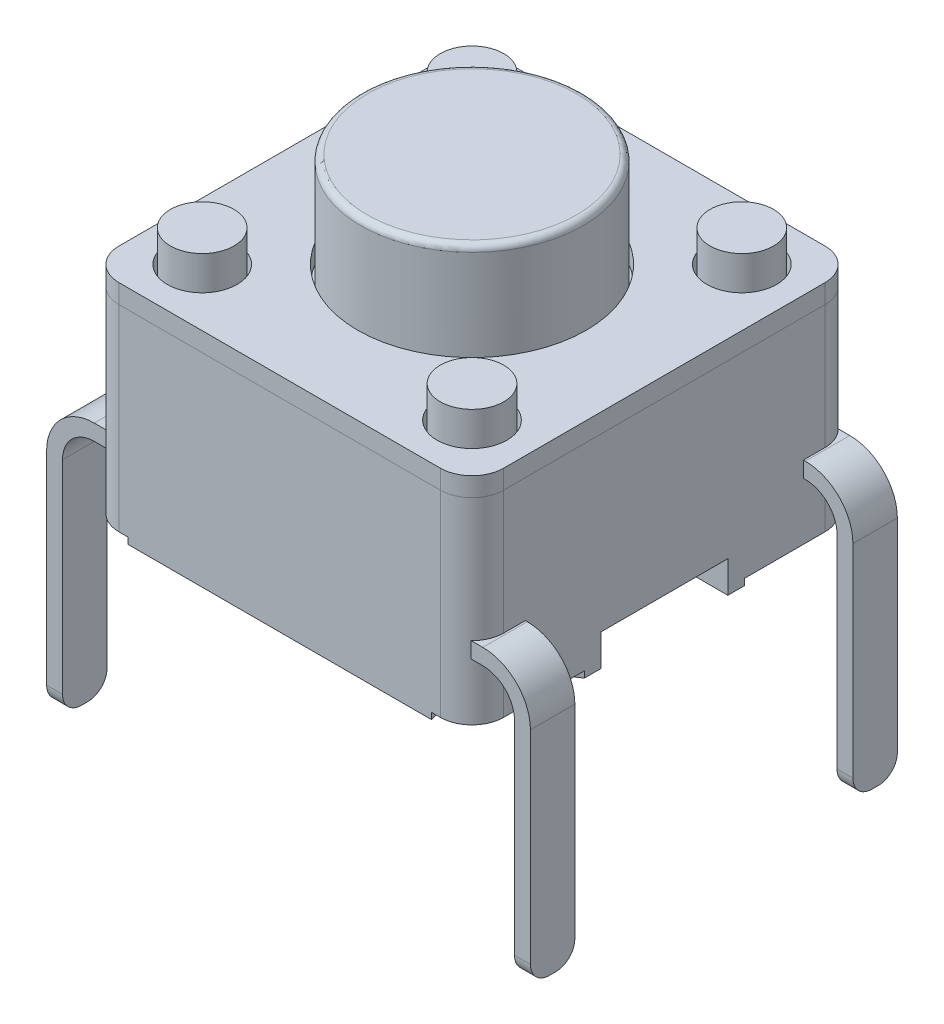
from build123d import *

# Parameters (mm, degrees)
SKETCH1_W           = 6.06
SKETCH1_H           = 6.06
BOSS_EXTRUDE1_DEPTH = 0.3
SKETCH2_W           = 6.06
SKETCH2_H           = 6.06
BOSS_EXTRUDE2_DEPTH = 3.2
SKETCH3_R           = 1.8
SKETCH3_R_2         = 0.55
CUT_EXTRUDE1_DEPTH  = 0.3
FILLET1_R           = 0.5
FILLET2_R           = 0.5
SKETCH5_R           = 0.5
BOSS_EXTRUDE4_DEPTH = 0.8
SKETCH6_R           = 1.75
BOSS_EXTRUDE5_DEPTH = 1.8
FILLET4_R           = 0.1
SKETCH7_W           = 2
SKETCH7_H           = 0.5
CUT_EXTRUDE2_DEPTH  = 6.06
EXTRUDE_THIN1_DEPTH = 0.35
FILLET5_R           = 0.3
LPATTERN1_COUNT     = 2
LPATTERN1_PITCH     = 5.08
SKETCH9_R           = 1.5
CUT_EXTRUDE4_DEPTH  = 0.1


with BuildPart() as part:
    # Sketch1 → Boss-Extrude1 (new body)
    with BuildSketch(Plane(origin=(0, 0, 0), x_dir=(1, 0, 0), z_dir=(0, 1, 0))):
        Rectangle(SKETCH1_W, SKETCH1_H)
    extrude(amount=-BOSS_EXTRUDE1_DEPTH)

    # Sketch3 → Cut-Extrude1 (cut)
    with BuildSketch(Plane(origin=(0, 0, 0), x_dir=(1, 0, 0), z_dir=(0, 1, 0))):
        Circle(SKETCH3_R)
        with Locations((2.125, 2.125)):
            Circle(SKETCH3_R_2)
        with Locations((2.125, -2.125)):
            Circle(SKETCH3_R_2)
        with Locations((-2.125, -2.125)):
            Circle(SKETCH3_R_2)
        with Locations((-2.125, 2.125)):
            Circle(SKETCH3_R_2)
    extrude(amount=-CUT_EXTRUDE1_DEPTH, mode=Mode.SUBTRACT)

    # Fillet1
    fillet1_edges = [part.edges().sort_by_distance(p)[0] for p in [
        (3.03, -0.15, 3.03),
        (-3.03, -0.15, 3.03),
        (-3.03, -0.15, -3.03),
        (3.03, -0.15, -3.03),
    ]]
    fillet(fillet1_edges, radius=FILLET1_R)


with BuildPart() as body_2:
    # Sketch2 → Boss-Extrude2 (new body)
    with BuildSketch(Plane.XZ.offset(0.3)):
        Rectangle(SKETCH2_W, SKETCH2_H)
    extrude(amount=BOSS_EXTRUDE2_DEPTH)

    # Fillet2
    fillet2_edges = [body_2.edges().sort_by_distance(p)[0] for p in [
        (-3.03, -1.9, -3.03),
        (-3.03, -1.9, 3.03),
        (3.03, -1.9, 3.03),
        (3.03, -1.9, -3.03),
    ]]
    fillet(fillet2_edges, radius=FILLET2_R)

    # Sketch5 → Boss-Extrude4 (add)
    with BuildSketch(Plane(origin=(0, -0.3, 0), x_dir=(1, 0, 0), z_dir=(0, 1, 0))):
        with Locations((-2.125, 2.125)):
            Circle(SKETCH5_R)
        with Locations((2.125, 2.125)):
            Circle(SKETCH5_R)
        with Locations((2.125, -2.125)):
            Circle(SKETCH5_R)
        with Locations((-2.125, -2.125)):
            Circle(SKETCH5_R)
    extrude(amount=BOSS_EXTRUDE4_DEPTH)

    # Sketch7 → Cut-Extrude2 (cut)
    with BuildSketch(Plane(origin=(3.03, 0, 0), x_dir=(0, 0, -1), z_dir=(1, 0, 0))):
        with Locations((0, -3.25)):
            Rectangle(SKETCH7_W, SKETCH7_H)
    extrude(amount=-CUT_EXTRUDE2_DEPTH, mode=Mode.SUBTRACT)

    # Sketch9 → Cut-Extrude4 (cut)
    with BuildSketch(Plane.XZ.offset(3.5)):
        with Locations((-3.81, 2.54)):
            Circle(SKETCH9_R)
        with Locations((3.81, 2.54)):
            Circle(SKETCH9_R)
        with Locations((3.81, -2.54)):
            Circle(SKETCH9_R)
        with Locations((-3.81, -2.54)):
            Circle(SKETCH9_R)
    extrude(amount=-CUT_EXTRUDE4_DEPTH, mode=Mode.SUBTRACT)


with BuildPart() as body_3:
    # Sketch6 → Boss-Extrude5 (new body)
    with BuildSketch(Plane(origin=(0, -0.3, 0), x_dir=(1, 0, 0), z_dir=(0, 1, 0))):
        Circle(SKETCH6_R)
    extrude(amount=BOSS_EXTRUDE5_DEPTH)

    # Fillet4
    fillet4_edges = [body_3.edges().sort_by_distance(p)[0] for p in [
        (-1.75, 1.5, 0),
    ]]
    fillet(fillet4_edges, radius=FILLET4_R)


with BuildPart() as body_4:
    # Sketch8 → Extrude-Thin1 (new body, symmetric)
    with BuildSketch(Plane.XY.offset(2.54)):
        with BuildLine():
            Line((-3.81, -6.5), (-3.81, -3))
            ThreePointArc((-3.81, -3), (-3.590330086, -2.469669914), (-3.06, -2.25))
            Line((-3.06, -2.25), (3.06, -2.25))
            ThreePointArc((3.06, -2.25), (3.590330086, -2.469669914), (3.81, -3))
            Line((3.81, -3), (3.81, -6.5))
            Line((3.81, -6.5), (3.56, -6.5))
            Line((3.56, -6.5), (3.56, -3))
            ThreePointArc((3.56, -3), (3.413553391, -2.646446609), (3.06, -2.5))
            Line((3.06, -2.5), (-3.06, -2.5))
            ThreePointArc((-3.06, -2.5), (-3.413553391, -2.646446609), (-3.56, -3))
            Line((-3.56, -3), (-3.56, -6.5))
            Line((-3.56, -6.5), (-3.81, -6.5))
        make_face()
    extrude(amount=EXTRUDE_THIN1_DEPTH, both=True)

    # Fillet5
    fillet5_edges = [body_4.edges().sort_by_distance(p)[0] for p in [
        (3.685, -6.5, 2.89),
        (-3.685, -6.5, 2.89),
        (3.685, -6.5, 2.19),
        (-3.685, -6.5, 2.19),
    ]]
    fillet(fillet5_edges, radius=FILLET5_R)


with BuildPart() as lpattern1_1:
    # LPattern1: pattern copy
    add(body_4.part.moved(Location(Vector(0, 0, -1) * (1 * LPATTERN1_PITCH))))


solid = Compound([part.part, body_2.part, body_3.part, body_4.part, lpattern1_1.part])
